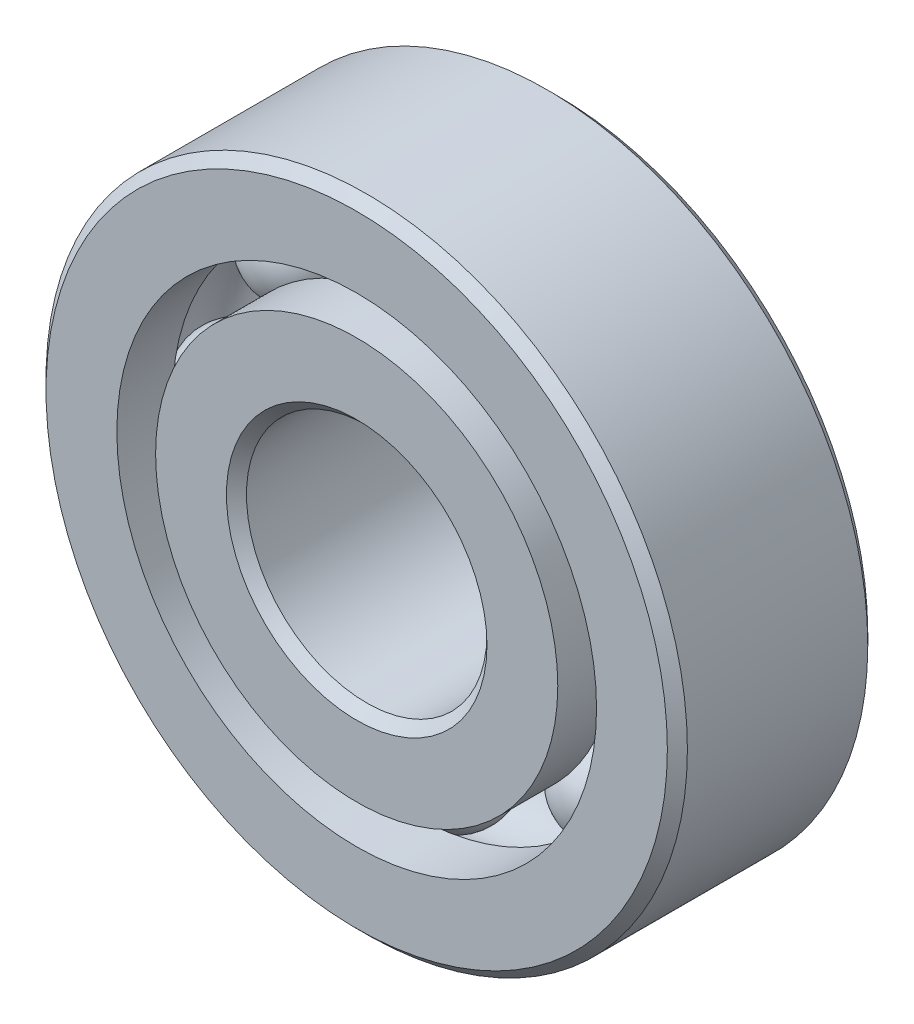
from build123d import *

# Parameters (mm, degrees)
CIRPATTERN1_COUNT = 8


with BuildPart() as part:
    # Sketch1 → Revolve1 (revolve)
    with BuildSketch(Plane(origin=(0, 0, 0), x_dir=(0, 0, -1), z_dir=(1, 0, 0))):
        with BuildLine():
            Line((1.7859375, 6.35), (-1.7859375, 6.35))
            Line((-1.7859375, 6.35), (-1.984375, 6.1515625))
            Line((-1.984375, 6.1515625), (-1.984375, 4.749416209))
            Line((-1.984375, 4.749416209), (-0.881944444, 4.749416209))
            ThreePointArc((-0.881944444, 4.749416209), (0, 5.327457467), (0.881944444, 4.749416209))
            Line((0.881944444, 4.749416209), (1.984375, 4.749416209))
            Line((1.984375, 4.749416209), (1.984375, 6.1515625))
            Line((1.984375, 6.1515625), (1.7859375, 6.35))
        make_face()
    revolve(axis=Axis((0, 0, 1.984375), (0, 0, -1)))


with BuildPart() as body_2:
    # Sketch3 → Revolve3 (revolve)
    with BuildSketch(Plane(origin=(0, 0, 0), x_dir=(0, 0, -1), z_dir=(1, 0, 0))):
        with BuildLine():
            Line((-1.984375, 3.981833791), (-0.881944444, 3.981833791))
            ThreePointArc((-0.881944444, 3.981833791), (0, 3.403792533), (0.881944444, 3.981833791))
            Line((0.881944444, 3.981833791), (1.984375, 3.981833791))
            Line((1.984375, 3.981833791), (1.984375, 2.5796875))
            Line((1.984375, 2.5796875), (1.7859375, 2.38125))
            Line((1.7859375, 2.38125), (-1.7859375, 2.38125))
            Line((-1.7859375, 2.38125), (-1.984375, 2.5796875))
            Line((-1.984375, 2.5796875), (-1.984375, 3.981833791))
        make_face()
    revolve(axis=Axis((0, 0, 1.984375), (0, 0, -1)))


with BuildPart() as body_3:
    # Sketch4 → Revolve4 (revolve)
    with BuildSketch(Plane(origin=(0, 0, 0), x_dir=(0, 0, -1), z_dir=(1, 0, 0))):
        with BuildLine():
            Line((-0.961832467, 4.365625), (0.961832467, 4.365625))
            ThreePointArc((0.961832467, 4.365625), (0, 5.327457467), (-0.961832467, 4.365625))
        make_face()
    revolve(axis=Axis((0, 4.365625, 0.961832467), (0, 0, -1)))


with BuildPart() as cirpattern1_1:
    # CirPattern1: pattern copy
    add(body_3.part.rotate(Axis((0, 0, 0), (0, 0, 1)), 1 * 360 / CIRPATTERN1_COUNT))


with BuildPart() as cirpattern1_2:
    # CirPattern1: pattern copy
    add(body_3.part.rotate(Axis((0, 0, 0), (0, 0, 1)), 2 * 360 / CIRPATTERN1_COUNT))


with BuildPart() as cirpattern1_3:
    # CirPattern1: pattern copy
    add(body_3.part.rotate(Axis((0, 0, 0), (0, 0, 1)), 3 * 360 / CIRPATTERN1_COUNT))


with BuildPart() as cirpattern1_4:
    # CirPattern1: pattern copy
    add(body_3.part.rotate(Axis((0, 0, 0), (0, 0, 1)), 4 * 360 / CIRPATTERN1_COUNT))


with BuildPart() as cirpattern1_5:
    # CirPattern1: pattern copy
    add(body_3.part.rotate(Axis((0, 0, 0), (0, 0, 1)), 5 * 360 / CIRPATTERN1_COUNT))


with BuildPart() as cirpattern1_6:
    # CirPattern1: pattern copy
    add(body_3.part.rotate(Axis((0, 0, 0), (0, 0, 1)), 6 * 360 / CIRPATTERN1_COUNT))


with BuildPart() as cirpattern1_7:
    # CirPattern1: pattern copy
    add(body_3.part.rotate(Axis((0, 0, 0), (0, 0, 1)), 7 * 360 / CIRPATTERN1_COUNT))


solid = Compound([part.part, body_2.part, body_3.part, cirpattern1_1.part, cirpattern1_2.part, cirpattern1_3.part, cirpattern1_4.part, cirpattern1_5.part, cirpattern1_6.part, cirpattern1_7.part])
